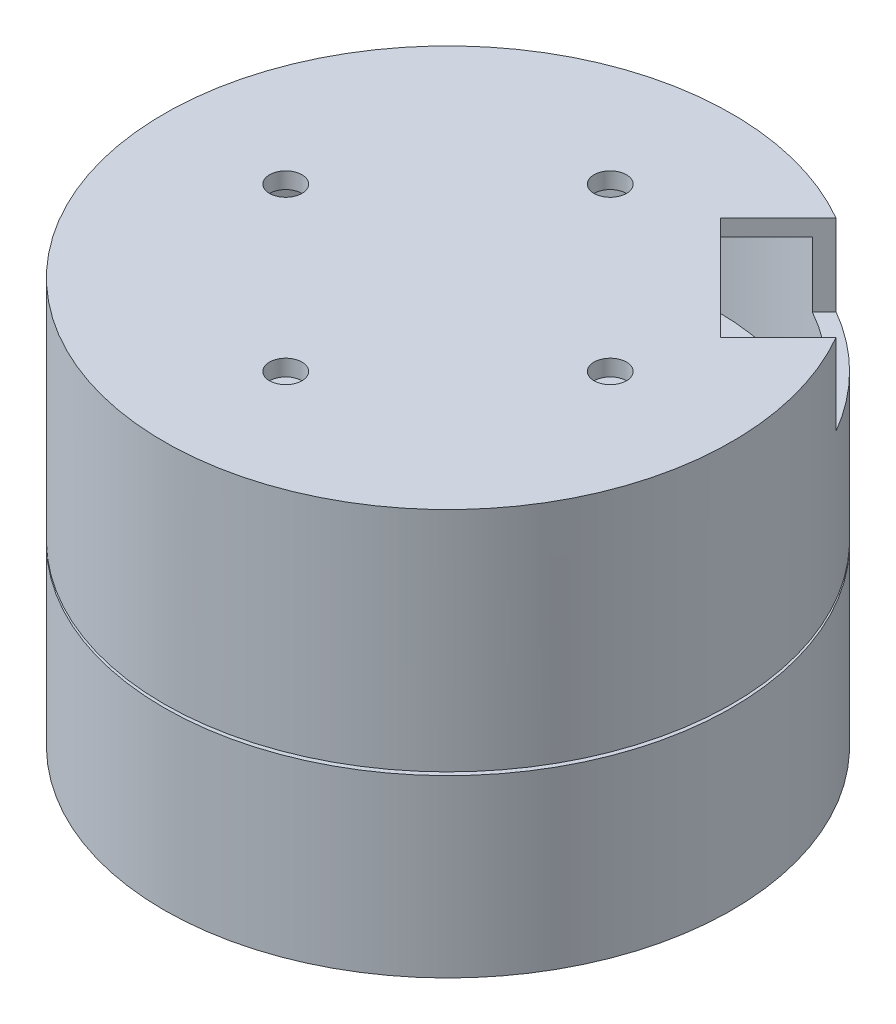
from build123d import *

# Parameters (mm, degrees)
SKETCH1_R           = 17.5
BOSS_EXTRUDE1_DEPTH = 15
BOSS_EXTRUDE2_DEPTH = 2
CUT_EXTRUDE1_REACH  = 19
SKETCH3_R           = 3.25
SKETCH4_R           = 1
CUT_EXTRUDE2_DEPTH  = 5
CIRPATTERN1_COUNT   = 4
SKETCH5_R           = 1
CUT_EXTRUDE3_DEPTH  = 2
CIRPATTERN2_COUNT   = 4
SKETCH6_R           = 7.5
CUT_EXTRUDE4_DEPTH  = 5
CUT_EXTRUDE6_START  = -4
SKETCH7_R           = 17.5
SKETCH7_R_2         = 12.5
CUT_EXTRUDE6_DEPTH  = 0.2
FILLET1_R           = 2
CUT_EXTRUDE7_DEPTH  = 3
SKETCH9_R           = 17.5
SKETCH9_R_2         = 16.5
BOSS_EXTRUDE3_DEPTH = 10
SKETCH10_R          = 16.5
BOSS_EXTRUDE4_DEPTH = 1
CUT_EXTRUDE8_DEPTH  = 5
SKETCH12_R          = 1
CUT_EXTRUDE9_DEPTH  = 1
CIRPATTERN3_COUNT   = 4


with BuildPart() as part:
    # Sketch1 → Boss-Extrude1 (new body)
    with BuildSketch(Plane(origin=(0, 0, 0), x_dir=(1, 0, 0), z_dir=(0, 1, 0))):
        Circle(SKETCH1_R)
    extrude(amount=BOSS_EXTRUDE1_DEPTH)

    # Sketch2 → Boss-Extrude2 (add)
    with BuildSketch(Plane(origin=(0, 15, 0), x_dir=(1, 0, 0), z_dir=(0, 1, 0))):
        Polygon((7.3, 0), (3.65, 6.321985448), (-3.65, 6.321985448), (-7.3, 0), (-3.65, -6.321985448), (3.65, -6.321985448), align=None)
    extrude(amount=BOSS_EXTRUDE2_DEPTH)

    # Sketch3 → Cut-Extrude1 (cut, up to next)
    with BuildSketch(Plane.XZ, mode=Mode.PRIVATE) as cut_extrude1_sk1:
        Circle(SKETCH3_R)
    cut_extrude1_tool1 = extrude(cut_extrude1_sk1.sketch, amount=-CUT_EXTRUDE1_REACH, mode=Mode.PRIVATE) & part.part
    add(cut_extrude1_tool1.solids().sort_by_distance((0, 0, 0))[0], mode=Mode.SUBTRACT)

    # Sketch4 → Cut-Extrude2 (cut)
    with BuildSketch(Plane.XZ):
        with Locations((0, 9.5)):
            Circle(SKETCH4_R)
    cut_extrude2 = extrude(amount=-CUT_EXTRUDE2_DEPTH, mode=Mode.SUBTRACT)

    # CirPattern1: Cut-Extrude2 ×4 about axis
    cirpattern1_axis = Axis((0, 0, 0), (0, 1, 0))
    for i in range(1, CIRPATTERN1_COUNT):
        add(cut_extrude2.rotate(cirpattern1_axis, i * 360 / CIRPATTERN1_COUNT), mode=Mode.SUBTRACT)

    # Sketch5 → Cut-Extrude3 (cut)
    with BuildSketch(Plane(origin=(0, 15, 0), x_dir=(1, 0, 0), z_dir=(0, 1, 0))):
        with Locations((0, 14.5)):
            Circle(SKETCH5_R)
    cut_extrude3 = extrude(amount=-CUT_EXTRUDE3_DEPTH, mode=Mode.SUBTRACT)

    # CirPattern2: Cut-Extrude3 ×4 about axis
    cirpattern2_axis = Axis((0, 0, 0), (0, 1, 0))
    for i in range(1, CIRPATTERN2_COUNT):
        add(cut_extrude3.rotate(cirpattern2_axis, i * 360 / CIRPATTERN2_COUNT), mode=Mode.SUBTRACT)

    # Sketch6 → Cut-Extrude4 (cut)
    with BuildSketch(Plane(origin=(0, 15, 0), x_dir=(1, 0, 0), z_dir=(0, 1, 0))):
        Circle(SKETCH6_R)
        Polygon((7.3, 0), (3.65, 6.321985448), (-3.65, 6.321985448), (-7.3, 0), (-3.65, -6.321985448), (3.65, -6.321985448), align=None, mode=Mode.SUBTRACT)
    extrude(amount=-CUT_EXTRUDE4_DEPTH, mode=Mode.SUBTRACT)

    # Sketch7 → Cut-Extrude6 (cut)
    with BuildSketch(Plane(origin=(0, 15, 0), x_dir=(1, 0, 0), z_dir=(0, 1, 0)).offset(CUT_EXTRUDE6_START)):
        Circle(SKETCH7_R)
        Circle(SKETCH7_R_2, mode=Mode.SUBTRACT)
    extrude(amount=-CUT_EXTRUDE6_DEPTH, mode=Mode.SUBTRACT)

    # Fillet1
    fillet1_edges = [part.edges().sort_by_distance(p)[0] for p in [
        (-7.3, 13.5, 0),
        (-3.65, 13.5, 6.321985448),
        (3.65, 13.5, 6.321985448),
        (7.3, 13.5, 0),
        (3.65, 13.5, -6.321985448),
        (-3.65, 13.5, -6.321985448),
    ]]
    fillet(fillet1_edges, radius=FILLET1_R)

    # Sketch8 → Cut-Extrude7 (cut)
    with BuildSketch(Plane(origin=(0, 15, 0), x_dir=(1, 0, 0), z_dir=(0, 1, 0))):
        with BuildLine():
            Line((8.042991645, 14.406952676), (5.21456452, 11.578525551))
            Line((5.21456452, 11.578525551), (11.578525551, 5.21456452))
            Line((11.578525551, 5.21456452), (14.406952676, 8.042991645))
            ThreePointArc((14.406952676, 8.042991645), (11.66726189, 11.66726189), (8.042991645, 14.406952676))
        make_face()
    extrude(amount=-CUT_EXTRUDE7_DEPTH, mode=Mode.SUBTRACT)

    # Sketch9 → Boss-Extrude3 (add)
    with BuildSketch(Plane(origin=(0, 15, 0), x_dir=(1, 0, 0), z_dir=(0, 1, 0))):
        Circle(SKETCH9_R)
        Circle(SKETCH9_R_2, mode=Mode.SUBTRACT)
    extrude(amount=BOSS_EXTRUDE3_DEPTH)

    # Sketch10 → Boss-Extrude4 (add)
    with BuildSketch(Plane(origin=(0, 25, 0), x_dir=(1, 0, 0), z_dir=(0, 1, 0))):
        Circle(SKETCH10_R)
    extrude(amount=-BOSS_EXTRUDE4_DEPTH)

    # Sketch11 → Cut-Extrude8 (cut)
    with BuildSketch(Plane(origin=(0, 25, 0), x_dir=(1, 0, 0), z_dir=(0, 1, 0))):
        with BuildLine():
            Line((5.21456452, 11.578525551), (11.578525551, 5.21456452))
            Line((11.578525551, 5.21456452), (15.140241258, 8.776280228))
            ThreePointArc((15.140241258, 8.776280228), (12.374368671, 12.374368671), (8.776280228, 15.140241258))
            Line((8.776280228, 15.140241258), (5.21456452, 11.578525551))
        make_face()
    extrude(amount=-CUT_EXTRUDE8_DEPTH, mode=Mode.SUBTRACT)

    # Sketch12 → Cut-Extrude9 (cut)
    with BuildSketch(Plane(origin=(0, 25, 0), x_dir=(1, 0, 0), z_dir=(0, 1, 0))):
        with Locations((0, 10)):
            Circle(SKETCH12_R)
    cut_extrude9 = extrude(amount=-CUT_EXTRUDE9_DEPTH, mode=Mode.SUBTRACT)

    # CirPattern3: Cut-Extrude9 ×4 about axis
    cirpattern3_axis = Axis((0, 0, 0), (0, 1, 0))
    for i in range(1, CIRPATTERN3_COUNT):
        add(cut_extrude9.rotate(cirpattern3_axis, i * 360 / CIRPATTERN3_COUNT), mode=Mode.SUBTRACT)


solid = part.part
